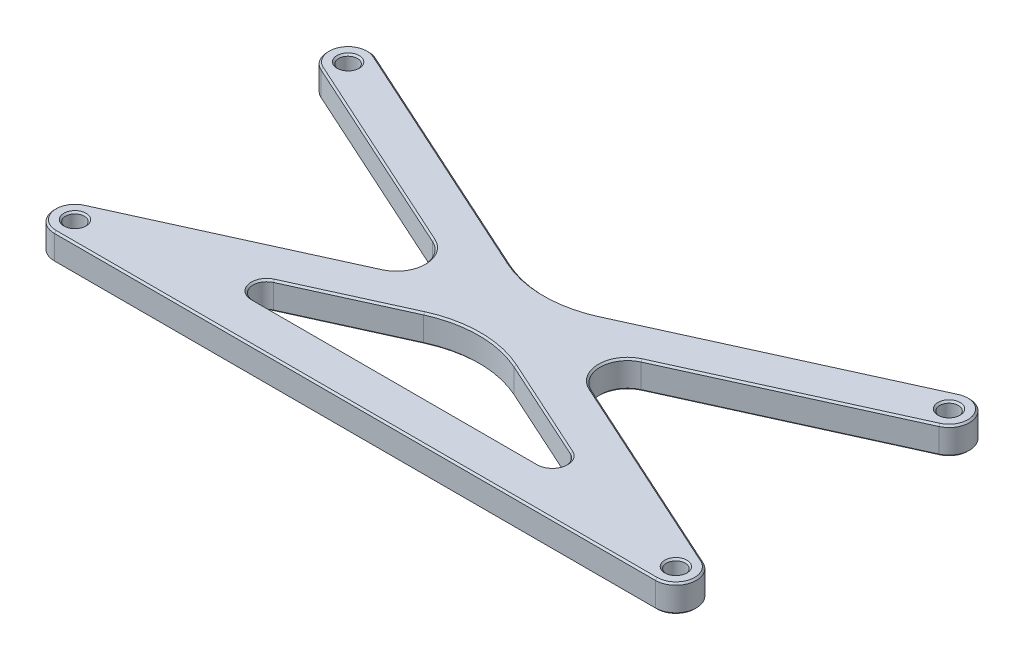
from build123d import *

# Parameters (mm, degrees)
SKETCH1_R           = 2.1828125
BOSS_EXTRUDE1_DEPTH = 6.35
FILLET1_R           = 25.4
FILLET2_R           = 3.175
FILLET3_R           = 6.35
CHAMFER1_SIZE       = 0.396875


with BuildPart() as part:
    # Sketch1 → Boss-Extrude1 (new body)
    with BuildSketch(Plane(origin=(0, 0, 0), x_dir=(1, 0, 0), z_dir=(0, 1, 0))):
        with BuildLine():
            Line((-69.85, -4.7625), (69.85, -4.7625))
            ThreePointArc((69.85, -4.7625), (74.504556808, -1.008219802), (71.820736522, 4.335620349))
            Line((71.820736522, 4.335620349), (11.50910129, 31.75))
            Line((11.50910129, 31.75), (71.820736522, 59.164379651))
            ThreePointArc((71.820736522, 59.164379651), (74.185620349, 65.470736522), (67.879263478, 67.835620349))
            Line((67.879263478, 67.835620349), (0, 36.981409677))
            Line((0, 36.981409677), (-67.879263478, 67.835620349))
            ThreePointArc((-67.879263478, 67.835620349), (-74.185620349, 65.470736522), (-71.820736522, 59.164379651))
            Line((-71.820736522, 59.164379651), (-11.50910129, 31.75))
            Line((-11.50910129, 31.75), (-71.820736522, 4.335620349))
            ThreePointArc((-71.820736522, 4.335620349), (-74.504556808, -1.008219802), (-69.85, -4.7625))
        make_face()
        with Locations((-69.85, 0)):
            Circle(SKETCH1_R, mode=Mode.SUBTRACT)
        with Locations((69.85, 0)):
            Circle(SKETCH1_R, mode=Mode.SUBTRACT)
        with Locations((-69.85, 63.5)):
            Circle(SKETCH1_R, mode=Mode.SUBTRACT)
        with Locations((69.85, 63.5)):
            Circle(SKETCH1_R, mode=Mode.SUBTRACT)
        Polygon((-47.86339871, 4.7625), (47.86339871, 4.7625), (0, 26.518590323), align=None, mode=Mode.SUBTRACT)
    extrude(amount=BOSS_EXTRUDE1_DEPTH)

    # Fillet1
    fillet1_edges = [part.edges().sort_by_distance(p)[0] for p in [
        (0, 3.175, -36.981409677),
        (0, 3.175, -26.518590323),
    ]]
    fillet(fillet1_edges, radius=FILLET1_R)

    # Fillet2
    fillet2_edges = [part.edges().sort_by_distance(p)[0] for p in [
        (47.86339871, 3.175, -4.7625),
        (-47.86339871, 3.175, -4.7625),
    ]]
    fillet(fillet2_edges, radius=FILLET2_R)

    # Fillet3
    fillet3_edges = [part.edges().sort_by_distance(p)[0] for p in [
        (-11.50910129, 3.175, -31.75),
        (11.50910129, 3.175, -31.75),
    ]]
    fillet(fillet3_edges, radius=FILLET3_R)

    # Chamfer1
    chamfer1_edges = [part.edges().sort_by_distance(p)[0] for p in [
        (-48.023828751, 0, -48.347603391),
        (-74.185620349, 0, -65.470736522),
        (39.194929132, 0, -54.797286555),
        (74.504556808, 6.35, 1.008219802),
        (74.185620349, 0, -65.470736522),
        (48.023828751, 0, -15.152396609),
        (74.504556808, 0, 1.008219802),
        (0, 0, 4.7625),
        (-74.504556808, 0, 1.008219802),
        (48.023828751, 6.35, -15.152396609),
        (74.185620349, 6.35, -65.470736522),
        (-72.0328125, 0, 0),
        (-72.0328125, 6.35, 0),
        (39.194929132, 6.35, -54.797286555),
        (67.6671875, 0, 0),
        (67.6671875, 6.35, 0),
        (67.6671875, 0, -63.5),
        (67.6671875, 6.35, -63.5),
        (-74.185620349, 6.35, -65.470736522),
        (-72.0328125, 0, -63.5),
        (-72.0328125, 6.35, -63.5),
        (-48.023828751, 6.35, -48.347603391),
        (-74.504556808, 6.35, 1.008219802),
        (-22.515041825, 0, -16.284480402),
        (-22.515041825, 6.35, -16.284480402),
        (-39.194929132, 0, -54.797286555),
        (-39.194929132, 6.35, -54.797286555),
        (0, 0, -24.017738711),
        (0, 6.35, -24.017738711),
        (0, 0, -39.482261289),
        (0, 6.35, -39.482261289),
        (0, 0, -4.7625),
        (0, 6.35, -4.7625),
        (22.515041825, 6.35, -16.284480402),
        (22.515041825, 0, -16.284480402),
        (36.308702389, 0, -7.265353465),
        (36.308702389, 6.35, -7.265353465),
        (-36.308702389, 0, -7.265353465),
        (-36.308702389, 6.35, -7.265353465),
        (-48.023828751, 0, -15.152396609),
        (-48.023828751, 6.35, -15.152396609),
        (48.023828751, 0, -48.347603391),
        (48.023828751, 6.35, -48.347603391),
        (-20.504569676, 0, -31.75),
        (0, 6.35, 4.7625),
        (-20.504569676, 6.35, -31.75),
        (20.504569676, 0, -31.75),
        (20.504569676, 6.35, -31.75),
    ]]
    chamfer(chamfer1_edges, length=CHAMFER1_SIZE)


solid = part.part
